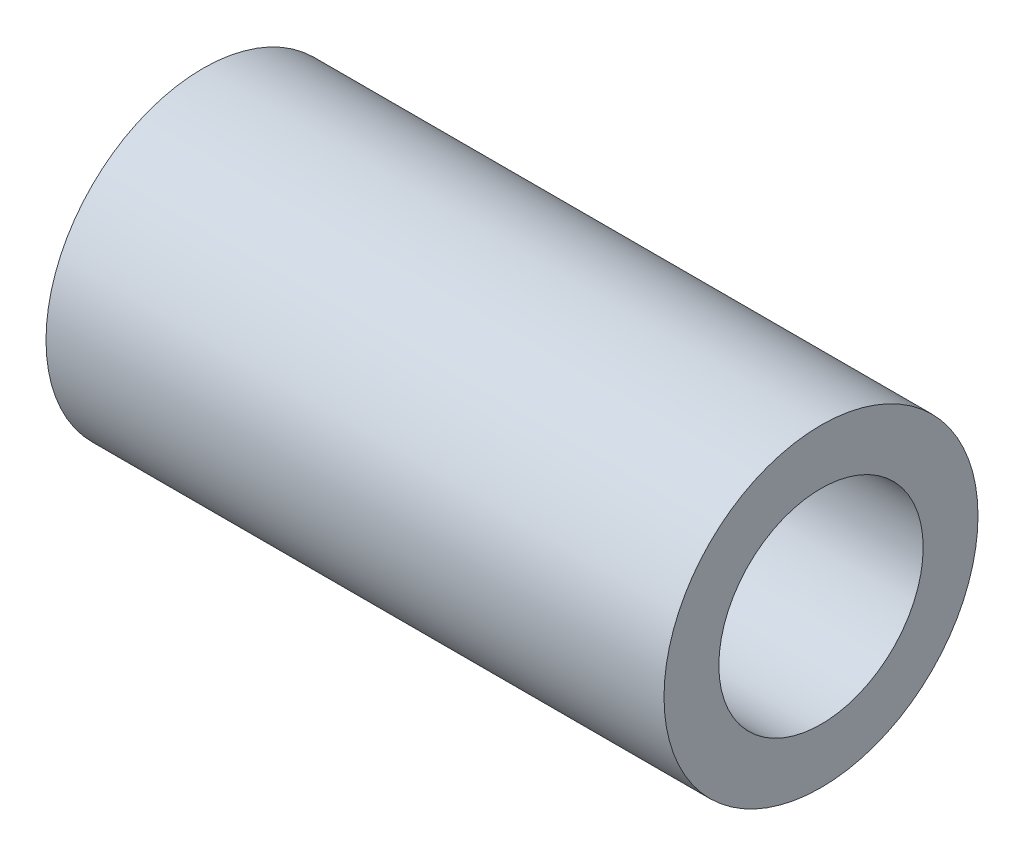
from build123d import *

# Parameters (mm, degrees)
CROQUIS1_W = 24.8
CROQUIS1_H = 2.2


with BuildPart() as part:
    # Croquis1 → Revolución1 (revolve)
    with BuildSketch(Plane.XY):
        with Locations((0, 5.2)):
            Rectangle(CROQUIS1_W, CROQUIS1_H)
    revolve(axis=Axis((-12.4, 0, 0), (1, 0, 0)))


solid = part.part
